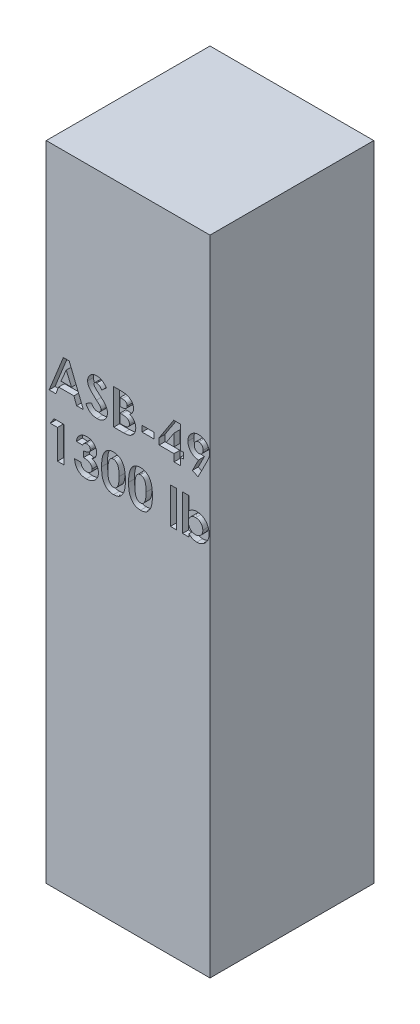
from build123d import *

# Parameters (mm, degrees)
SKETCH1_W           = 355.6
SKETCH1_H           = 1397
BOSS_EXTRUDE1_DEPTH = 355.6
SKETCH2_W           = 26.376923077
SKETCH2_H           = 12.7
SKETCH2_W_2         = 13.676923077
SKETCH2_H_2         = 78.153846154
CUT_EXTRUDE1_DEPTH  = 12.7


with BuildPart() as part:
    # Sketch1 → Boss-Extrude1 (new body)
    with BuildSketch(Plane.XY):
        Rectangle(SKETCH1_W, SKETCH1_H)
    extrude(amount=BOSS_EXTRUDE1_DEPTH)

    # Sketch2 → Cut-Extrude1 (cut)
    with BuildSketch(Plane.XY.offset(355.6)):
        Polygon((-140.661658654, 309.033333333), (-127.976923077, 309.033333333), (-97.203846154, 232.833333333), (-111.811899038, 232.833333333), (-117.734495192, 248.464102564), (-150.934615385, 248.464102564), (-156.857211538, 232.833333333), (-171.45, 232.833333333), align=None)
        Polygon((-134.326923077, 288.594270833), (-145.744711538, 262.141025641), (-122.909134615, 262.141025641), align=None, mode=Mode.SUBTRACT)
        with BuildLine():
            Line((-46.892307692, 298.851963141), (-57.119471154, 289.494871795))
            add(Edge.make_bspline(
                [(-57.119471154, 289.494871795), (-57.557558983, 290.112840222), (-58.398626523, 291.299253425), (-59.761909279, 292.887888667), (-61.119036113, 294.243112753), (-62.482579983, 295.359264183), (-63.86462682, 296.229561507), (-65.262777595, 296.845741626), (-66.669105798, 297.237453175), (-67.613941264, 297.286230688), (-68.079326923, 297.31025641)],
                knots=[0, 0, 0, 0, 0.002271477, 0.00436092, 0.006271414, 0.00801884, 0.009636869, 0.011154202, 0.012590762, 0.013985181, 0.013985181, 0.013985181, 0.013985181], degree=3))
            add(Edge.make_bspline(
                [(-68.079326923, 297.31025641), (-68.513425317, 297.29503261), (-69.351555263, 297.265639452), (-70.546371681, 296.973473654), (-71.607146713, 296.469238391), (-72.532845089, 295.809908365), (-73.266134779, 295.015568541), (-73.851609731, 294.182510307), (-74.181281326, 293.263002418), (-74.224672594, 292.631447308), (-74.246153846, 292.318790064)],
                knots=[0, 0, 0, 0, 0.001300704, 0.002511318, 0.003658488, 0.004806572, 0.005897204, 0.006887864, 0.007843812, 0.008781052, 0.008781052, 0.008781052, 0.008781052], degree=3))
            add(Edge.make_bspline(
                [(-74.246153846, 292.318790064), (-74.232692635, 292.001624164), (-74.205583625, 291.362896117), (-73.943747496, 290.426760617), (-73.549085685, 289.512047259), (-73.171970213, 288.955217713), (-72.979206731, 288.670592949)],
                knots=[0, 0, 0, 0, 0.000949467, 0.001912094, 0.002896265, 0.00392534, 0.00392534, 0.00392534, 0.00392534], degree=3))
            add(Edge.make_bspline(
                [(-72.979206731, 288.670592949), (-72.803963873, 288.449357098), (-72.400577959, 287.940101388), (-71.631403639, 287.133519725), (-70.665482233, 286.145386588), (-69.465643052, 285.009680978), (-68.081694719, 283.68555848), (-66.449489442, 282.225070854), (-64.616009207, 280.582988495), (-63.312813935, 279.439501804), (-62.629927885, 278.840304487)],
                knots=[0, 0, 0, 0, 0.000846316, 0.001948107, 0.00334052, 0.004992255, 0.00690348, 0.009086453, 0.011562161, 0.01428762, 0.01428762, 0.01428762, 0.01428762], degree=3))
            add(Edge.make_bspline(
                [(-62.629927885, 278.840304487), (-61.988941094, 278.285562752), (-60.772481336, 277.23277819), (-59.041700667, 275.738519539), (-57.520632718, 274.394171466), (-56.187118999, 273.219909758), (-55.061374278, 272.203413722), (-54.13866592, 271.339824518), (-53.407724607, 270.645954641), (-52.992227269, 270.226856812), (-52.814903846, 270.047996795)],
                knots=[0, 0, 0, 0, 0.002543119, 0.004826311, 0.006859633, 0.008633068, 0.010156836, 0.011409635, 0.012424461, 0.013180012, 0.013180012, 0.013180012, 0.013180012], degree=3))
            add(Edge.make_bspline(
                [(-52.814903846, 270.047996795), (-52.14217575, 269.319960917), (-50.848956097, 267.920420286), (-49.168226438, 265.751572454), (-47.784931563, 263.634334733), (-46.714788416, 261.528867861), (-45.90657327, 259.404794142), (-45.336770886, 257.210020781), (-44.995512446, 254.921613775), (-44.957624792, 253.360055353), (-44.938461538, 252.570232372)],
                knots=[0, 0, 0, 0, 0.002972646, 0.005714469, 0.008221044, 0.010548906, 0.012785704, 0.015025625, 0.017339784, 0.019708181, 0.019708181, 0.019708181, 0.019708181], degree=3))
            add(Edge.make_bspline(
                [(-44.938461538, 252.570232372), (-44.952101452, 251.80064674), (-44.978863469, 250.290691086), (-45.306646862, 248.081095904), (-45.774046742, 245.966417417), (-46.496728952, 243.969666317), (-47.37752975, 242.058066543), (-48.481740763, 240.261394741), (-49.778485188, 238.561467858), (-51.264753405, 236.988674166), (-52.908742539, 235.561472904), (-54.672077127, 234.290944631), (-56.571999943, 233.241961707), (-58.592278345, 232.378199091), (-60.731830923, 231.712917575), (-62.988108827, 231.221212531), (-65.364563186, 230.926098915), (-66.989616922, 230.895248288), (-67.819831731, 230.879487179)],
                knots=[0, 0, 0, 0, 0.002306747, 0.004525923, 0.006688305, 0.008793246, 0.010882856, 0.012992883, 0.015105559, 0.017286823, 0.019472356, 0.021628317, 0.023794413, 0.025969098, 0.028209175, 0.030505596, 0.032889291, 0.035379077, 0.035379077, 0.035379077, 0.035379077], degree=3))
            add(Edge.make_bspline(
                [(-67.819831731, 230.879487179), (-68.471543286, 230.891048977), (-69.762305921, 230.913947966), (-71.664694906, 231.100899151), (-73.501666523, 231.402618474), (-75.27115159, 231.835072394), (-76.981121948, 232.383050164), (-78.631647824, 233.052384018), (-80.211335089, 233.85344838), (-81.732136406, 234.769770182), (-83.186658805, 235.833740496), (-84.593294148, 237.023606796), (-85.938070399, 238.35766976), (-87.227446244, 239.832774378), (-88.453171897, 241.453097794), (-89.655369758, 243.196074005), (-90.780610535, 245.094050283), (-91.475721818, 246.425495996), (-91.830769231, 247.10556891)],
                knots=[0, 0, 0, 0, 0.0019548, 0.003871625, 0.005728622, 0.007535314, 0.009331074, 0.011111196, 0.012872436, 0.014639486, 0.01643174, 0.01827286, 0.020161767, 0.022108923, 0.02414528, 0.02625376, 0.028457977, 0.030759313, 0.030759313, 0.030759313, 0.030759313], degree=3))
            Line((-91.830769231, 247.10556891), (-79.802403846, 254.325641026))
            add(Edge.make_bspline(
                [(-79.802403846, 254.325641026), (-79.358292598, 253.553669411), (-78.506893378, 252.073733849), (-77.064117804, 250.085252851), (-75.586067886, 248.38244803), (-74.038572431, 246.995416571), (-72.440448407, 245.90561208), (-70.783976503, 245.126762185), (-69.067992913, 244.644654981), (-67.899142848, 244.585778556), (-67.316105769, 244.556410256)],
                knots=[0, 0, 0, 0, 0.002670183, 0.00511897, 0.007357642, 0.009422631, 0.011336233, 0.013139051, 0.014894194, 0.01664102, 0.01664102, 0.01664102, 0.01664102], degree=3))
            add(Edge.make_bspline(
                [(-67.316105769, 244.556410256), (-66.723073588, 244.580394002), (-65.572504787, 244.626925962), (-63.930215055, 245.056727645), (-62.424501645, 245.731547818), (-61.122974095, 246.69442315), (-60.020922626, 247.805727628), (-59.207545384, 249.042104674), (-58.696576314, 250.379834793), (-58.642554495, 251.309110127), (-58.615384615, 251.776482372)],
                knots=[0, 0, 0, 0, 0.001775994, 0.003445688, 0.005057657, 0.006697287, 0.008273297, 0.00972975, 0.011110822, 0.012508246, 0.012508246, 0.012508246, 0.012508246], degree=3))
            add(Edge.make_bspline(
                [(-58.615384615, 251.776482372), (-58.640474887, 252.21129619), (-58.691443372, 253.094578835), (-59.066861522, 254.407878095), (-59.653754599, 255.720580094), (-60.348090496, 256.797293787), (-61.054664213, 257.698796976), (-61.730308055, 258.479908709), (-62.553063524, 259.342900426), (-63.520844477, 260.288857706), (-64.620864002, 261.32610805), (-65.854048722, 262.454549887), (-67.234519907, 263.664242992), (-68.210239664, 264.488273984), (-68.720432692, 264.919150641)],
                knots=[0, 0, 0, 0, 0.00130321, 0.002647346, 0.004068578, 0.005605744, 0.00647595, 0.00750412, 0.008702644, 0.010051884, 0.011563602, 0.013238312, 0.015066286, 0.017069651, 0.017069651, 0.017069651, 0.017069651], degree=3))
            add(Edge.make_bspline(
                [(-68.720432692, 264.919150641), (-69.690329945, 265.739776722), (-71.551856338, 267.314806557), (-74.182429308, 269.641076041), (-76.552811092, 271.815188027), (-78.642528527, 273.864019293), (-80.478207847, 275.749732674), (-82.047417034, 277.487644654), (-83.332917611, 279.091160848), (-84.685629778, 280.990418475), (-85.970976795, 283.304794394), (-87.081881368, 286.089256921), (-87.802589366, 288.873366141), (-87.883334674, 290.742463725), (-87.923076923, 291.662419872)],
                knots=[0, 0, 0, 0, 0.00381134, 0.007315116, 0.010534208, 0.013459447, 0.016093434, 0.018428441, 0.020480981, 0.022255466, 0.025419366, 0.028392795, 0.031236119, 0.033992014, 0.033992014, 0.033992014, 0.033992014], degree=3))
            add(Edge.make_bspline(
                [(-87.923076923, 291.662419872), (-87.906548175, 292.314803393), (-87.873984765, 293.600069009), (-87.583514124, 295.489864828), (-87.149394685, 297.313359007), (-86.518928628, 299.063898607), (-85.700659811, 300.739291008), (-84.706904118, 302.347737961), (-83.522230405, 303.874435682), (-82.187183107, 305.31837208), (-80.716302795, 306.637965628), (-79.14448026, 307.802639158), (-77.480612156, 308.786339356), (-75.734877186, 309.6023901), (-73.896457756, 310.227025104), (-71.978897418, 310.66979753), (-69.979445783, 310.933144449), (-68.619461939, 310.968943407), (-67.926682692, 310.987179487)],
                knots=[0, 0, 0, 0, 0.001955992, 0.003853513, 0.00572314, 0.007572405, 0.009422488, 0.011307506, 0.013234031, 0.0152107, 0.017199649, 0.019153554, 0.021069832, 0.022988844, 0.024924539, 0.026883269, 0.028884539, 0.03096252, 0.03096252, 0.03096252, 0.03096252], degree=3))
            add(Edge.make_bspline(
                [(-67.926682692, 310.987179487), (-67.028875077, 310.954335772), (-65.240346824, 310.888907598), (-62.595956218, 310.377280657), (-60.013026035, 309.572693401), (-57.931652487, 308.602047396), (-56.275542405, 307.661782152), (-55.00628873, 306.796104358), (-53.714754796, 305.804423917), (-52.390525183, 304.683615784), (-51.058206129, 303.412562461), (-49.67991343, 302.021522372), (-48.274428009, 300.498473679), (-47.361085331, 299.410414755), (-46.892307692, 298.851963141)],
                knots=[0, 0, 0, 0, 0.00269178, 0.005362313, 0.008051322, 0.01079017, 0.01223288, 0.013761229, 0.015394594, 0.017116499, 0.018962989, 0.020916657, 0.022990822, 0.025177953, 0.025177953, 0.025177953, 0.025177953], degree=3))
        make_face()
        with BuildLine():
            Line((-31.261538462, 232.833333333), (-31.261538462, 309.033333333))
            Line((-31.261538462, 309.033333333), (-19.05, 309.033333333))
            add(Edge.make_bspline(
                [(-19.05, 309.033333333), (-18.195115952, 309.033430897), (-16.540931527, 309.03361968), (-14.154375105, 308.949811654), (-11.941045574, 308.841396583), (-9.907986607, 308.72010533), (-8.051737796, 308.511096267), (-6.375121871, 308.290823546), (-4.874788943, 308.02518822), (-3.947214621, 307.786905103), (-3.510817308, 307.674799679)],
                knots=[0, 0, 0, 0, 0.002564469, 0.004962198, 0.00716287, 0.009212911, 0.011070536, 0.012765162, 0.014286099, 0.01563741, 0.01563741, 0.01563741, 0.01563741], degree=3))
            add(Edge.make_bspline(
                [(-3.510817308, 307.674799679), (-2.937783327, 307.516672983), (-1.813306698, 307.206377641), (-0.202697319, 306.579722787), (1.325190345, 305.883151488), (2.768490784, 305.088493916), (4.118341559, 304.186156326), (5.369612777, 303.168977496), (6.549291262, 302.077786942), (7.615489324, 300.88217349), (8.579156703, 299.618786404), (9.416410878, 298.287956724), (10.143877446, 296.910033707), (10.726041247, 295.467677105), (11.164690734, 293.967529363), (11.485517138, 292.415996343), (11.693456092, 290.808168612), (11.713103596, 289.714310855), (11.723076923, 289.159054487)],
                knots=[0, 0, 0, 0, 0.001782281, 0.003497407, 0.005177603, 0.006817375, 0.008434611, 0.010041369, 0.011650517, 0.013250298, 0.014840877, 0.016412001, 0.017961848, 0.019509513, 0.021069549, 0.022644227, 0.024259229, 0.025924171, 0.025924171, 0.025924171, 0.025924171], degree=3))
            add(Edge.make_bspline(
                [(11.723076923, 289.159054487), (11.696999635, 288.4456958), (11.645669696, 287.041536873), (11.317770555, 284.97908145), (10.702908576, 283.029764632), (9.898376632, 281.157661245), (8.804464718, 279.369754249), (7.415408151, 277.666893743), (5.7537051, 275.996646099), (4.479087128, 274.995445301), (3.816105769, 274.474679487)],
                knots=[0, 0, 0, 0, 0.002140505, 0.004213322, 0.006241251, 0.008257657, 0.010312693, 0.012505889, 0.014837301, 0.017364428, 0.017364428, 0.017364428, 0.017364428], degree=3))
            add(Edge.make_bspline(
                [(3.816105769, 274.474679487), (4.353354056, 274.200418896), (5.406749309, 273.662669754), (6.902261098, 272.778770693), (8.286941767, 271.83863194), (9.566999803, 270.861169465), (10.715584526, 269.804947216), (11.780122926, 268.730826171), (12.708096204, 267.57726366), (13.537917877, 266.385374848), (14.259185388, 265.137901047), (14.887329856, 263.836948959), (15.417900956, 262.478074249), (15.867202287, 261.068192488), (16.202291338, 259.602454343), (16.420776526, 258.080335605), (16.588062442, 256.507027474), (16.601075714, 255.435329263), (16.607692308, 254.890424679)],
                knots=[0, 0, 0, 0, 0.001809333, 0.003547602, 0.005207217, 0.006828483, 0.008373813, 0.009885068, 0.011360751, 0.012808862, 0.014238349, 0.015678877, 0.017138686, 0.018611129, 0.0201145, 0.021642926, 0.023222554, 0.024856489, 0.024856489, 0.024856489, 0.024856489], degree=3))
            add(Edge.make_bspline(
                [(16.607692308, 254.890424679), (16.564755037, 253.849688079), (16.480018505, 251.795798573), (15.860466333, 248.78021707), (14.786359727, 245.921172292), (13.344056043, 243.230027306), (11.566860402, 240.784686344), (9.523595057, 238.64258889), (7.234831005, 236.82935095), (5.123169533, 235.605556007), (3.296748654, 234.78427516), (1.783958365, 234.27650755), (0.15925366, 233.806112404), (-1.607126148, 233.475791219), (-3.483159003, 233.173444948), (-5.487136343, 232.986770097), (-7.615312772, 232.860265151), (-9.077036337, 232.842492101), (-9.830288462, 232.833333333)],
                knots=[0, 0, 0, 0, 0.003121267, 0.006159807, 0.009188055, 0.012254419, 0.015292384, 0.018228951, 0.021108754, 0.02402266, 0.025526031, 0.027109416, 0.028805691, 0.030595864, 0.032495656, 0.034505117, 0.036630383, 0.038889982, 0.038889982, 0.038889982, 0.038889982], degree=3))
            Line((-9.830288462, 232.833333333), (-31.261538462, 232.833333333))
        make_face()
        with BuildLine():
            Line((-17.584615385, 295.356410256), (-17.584615385, 278.748717949))
            Line((-17.584615385, 278.748717949), (-13.951682692, 278.748717949))
            add(Edge.make_bspline(
                [(-13.951682692, 278.748717949), (-13.457934499, 278.75302362), (-12.504783494, 278.761335457), (-11.128057969, 278.868389037), (-9.847925563, 279.051029094), (-8.669241544, 279.305857918), (-7.581026041, 279.629453369), (-6.590230888, 280.018808386), (-5.701212433, 280.493863829), (-4.668378606, 281.201479873), (-3.576598771, 282.242768564), (-2.61551726, 283.747125823), (-2.049446668, 285.477130948), (-1.986401672, 286.697264518), (-1.953846154, 287.327323718)],
                knots=[0, 0, 0, 0, 0.001480964, 0.002858911, 0.004139031, 0.005357606, 0.006473163, 0.007541782, 0.008545642, 0.009489818, 0.011292636, 0.013028826, 0.014795547, 0.016681985, 0.016681985, 0.016681985, 0.016681985], degree=3))
            add(Edge.make_bspline(
                [(-1.953846154, 287.327323718), (-1.979896528, 287.917478842), (-2.030263879, 289.058520058), (-2.600224185, 290.660643546), (-3.485485218, 292.08045285), (-4.530660295, 293.052196208), (-5.514895725, 293.715868272), (-6.357658498, 294.152868065), (-7.282653925, 294.544065812), (-8.307788926, 294.843185144), (-9.427209419, 295.067633759), (-10.635477752, 295.232464387), (-11.934678606, 295.344655125), (-12.832039401, 295.352407831), (-13.2953125, 295.356410256)],
                knots=[0, 0, 0, 0, 0.001763421, 0.003409503, 0.005035648, 0.00674158, 0.007643344, 0.008592443, 0.00958463, 0.01065194, 0.011789523, 0.013007046, 0.014308915, 0.015698313, 0.015698313, 0.015698313, 0.015698313], degree=3))
            Line((-13.2953125, 295.356410256), (-17.584615385, 295.356410256))
        make_face(mode=Mode.SUBTRACT)
        with BuildLine():
            Line((-17.584615385, 266.048717949), (-17.584615385, 246.51025641))
            Line((-17.584615385, 246.51025641), (-13.646394231, 246.51025641))
            add(Edge.make_bspline(
                [(-13.646394231, 246.51025641), (-12.867802894, 246.514704474), (-11.370863894, 246.52325643), (-9.226501429, 246.626584407), (-7.276739857, 246.812814878), (-5.526745311, 247.045308619), (-3.973837343, 247.360301273), (-2.623265154, 247.760774065), (-1.456507397, 248.201363889), (-0.480560009, 248.745544633), (0.316733098, 249.378836073), (1.036206534, 250.026075136), (1.622820342, 250.772726545), (2.086960134, 251.586738624), (2.488672304, 252.447890724), (2.730956718, 253.389810526), (2.915423567, 254.384581786), (2.925575272, 255.072643553), (2.930769231, 255.424679487)],
                knots=[0, 0, 0, 0, 0.002335656, 0.004490591, 0.006437807, 0.008210124, 0.009784803, 0.011185475, 0.012432682, 0.013519462, 0.014520882, 0.015482056, 0.016416558, 0.017353799, 0.01828992, 0.019256533, 0.020262828, 0.021317068, 0.021317068, 0.021317068, 0.021317068], degree=3))
            add(Edge.make_bspline(
                [(2.930769231, 255.424679487), (2.91931506, 255.827238114), (2.897005417, 256.611314027), (2.714802289, 257.757324651), (2.383679689, 258.827201606), (1.966614618, 259.848303091), (1.386246413, 260.784070113), (0.696498635, 261.666886022), (-0.136892764, 262.466855947), (-1.074090011, 263.232365058), (-2.16723781, 263.902609757), (-3.416849037, 264.484165754), (-4.829712259, 264.969859907), (-6.41020397, 265.356569909), (-8.151395416, 265.684765343), (-10.065995382, 265.880734247), (-12.138058416, 266.026484934), (-13.574860644, 266.041138548), (-14.318028846, 266.048717949)],
                knots=[0, 0, 0, 0, 0.001207434, 0.002351757, 0.003467314, 0.004561678, 0.005650707, 0.006759244, 0.007914208, 0.009108545, 0.010383559, 0.011749277, 0.013236129, 0.014857682, 0.016627104, 0.018547087, 0.020627589, 0.022856666, 0.022856666, 0.022856666, 0.022856666], degree=3))
            Line((-14.318028846, 266.048717949), (-17.584615385, 266.048717949))
        make_face(mode=Mode.SUBTRACT)
        with Locations((43.473076924, 260.675641026)):
            Rectangle(SKETCH2_W, SKETCH2_H)
        Polygon((99.066105769, 310.987179487), (113.323076923, 310.987179487), (113.323076923, 261.164102564), (120.161538462, 261.164102564), (120.161538462, 248.464102564), (113.323076923, 248.464102564), (113.323076923, 232.833333333), (99.646153846, 232.833333333), (99.646153846, 248.464102564), (67.407692308, 248.464102564), (67.407692308, 262.308934295), align=None)
        Polygon((99.646153846, 261.164102564), (99.646153846, 287.098357372), (82.778966346, 261.164102564), align=None, mode=Mode.SUBTRACT)
        with BuildLine():
            Line((151.728365385, 230.879487179), (139.608413462, 236.98525641))
            Line((139.608413462, 236.98525641), (152.888461538, 263.117948718))
            add(Edge.make_bspline(
                [(152.888461538, 263.117948718), (152.103845813, 263.13794753), (150.563455308, 263.177210036), (148.295350461, 263.503481108), (146.126416403, 264.06044665), (144.031088544, 264.801908098), (142.038344607, 265.795913999), (140.124020978, 266.982207879), (138.314618366, 268.407522923), (136.601653245, 270.009635967), (135.037661343, 271.780489469), (133.680149456, 273.68501244), (132.4969217, 275.674892711), (131.576778896, 277.795053271), (130.837715516, 280.005979592), (130.297718544, 282.319115674), (129.994686525, 284.74461007), (129.952331227, 286.395375029), (129.930769231, 287.235737179)],
                knots=[0, 0, 0, 0, 0.002353148, 0.0046198, 0.00685592, 0.009062514, 0.011274328, 0.013523384, 0.015807342, 0.018172343, 0.020551733, 0.022881596, 0.025180197, 0.027483305, 0.029800281, 0.032166316, 0.03459734, 0.037118235, 0.037118235, 0.037118235, 0.037118235], degree=3))
            add(Edge.make_bspline(
                [(129.930769231, 287.235737179), (129.950769158, 288.050880184), (129.990178601, 289.657102609), (130.317477833, 292.014514417), (130.856127661, 294.277974162), (131.595135926, 296.447097316), (132.578943988, 298.507257103), (133.730466284, 300.490710846), (135.138150043, 302.356423028), (136.728353797, 304.112470318), (138.468747412, 305.718943531), (140.315158946, 307.131426071), (142.259193034, 308.312125753), (144.275866914, 309.303695671), (146.401633429, 310.04453503), (148.605772874, 310.603492836), (150.90470463, 310.926091374), (152.465171559, 310.966653842), (153.254807692, 310.987179487)],
                knots=[0, 0, 0, 0, 0.002444644, 0.00481712, 0.007123716, 0.009416684, 0.011676901, 0.013962338, 0.016285591, 0.018673924, 0.021061282, 0.023381525, 0.025635548, 0.027874793, 0.030110132, 0.032375858, 0.034687851, 0.037056248, 0.037056248, 0.037056248, 0.037056248], degree=3))
            add(Edge.make_bspline(
                [(153.254807692, 310.987179487), (154.08046779, 310.970184167), (155.704016656, 310.936765169), (158.080674172, 310.567999708), (160.354563885, 310.002246034), (162.534924976, 309.233837129), (164.594689182, 308.1909472), (166.551091549, 306.941036357), (168.397624461, 305.456449501), (170.114457516, 303.779977025), (171.675897992, 301.956499541), (173.059920687, 300.047758514), (174.22255851, 298.057486077), (175.174830004, 296.003444726), (175.916644704, 293.882416558), (176.42654777, 291.691392981), (176.765066854, 289.434120741), (176.803583569, 287.903523346), (176.823076923, 287.128886218)],
                knots=[0, 0, 0, 0, 0.002475144, 0.004867036, 0.007195698, 0.009498806, 0.011785669, 0.014106062, 0.016451822, 0.018880593, 0.021294545, 0.023645712, 0.025944313, 0.028198078, 0.030428356, 0.032672018, 0.03493867, 0.037261321, 0.037261321, 0.037261321, 0.037261321], degree=3))
            add(Edge.make_bspline(
                [(176.823076923, 287.128886218), (176.812439218, 286.538088874), (176.791012488, 285.34809019), (176.580328607, 283.563558171), (176.260678708, 281.774080143), (175.889657337, 280.269572949), (175.500693045, 279.001364768), (175.122186492, 277.925525319), (174.636551444, 276.731141535), (174.094291371, 275.410207732), (173.466290386, 273.968516367), (172.739528043, 272.412959273), (171.957927867, 270.72046599), (171.381811383, 269.563162157), (171.083653846, 268.964222756)],
                knots=[0, 0, 0, 0, 0.001771725, 0.003568653, 0.005383131, 0.007223111, 0.008212947, 0.009361944, 0.010643155, 0.012080364, 0.013645767, 0.015360078, 0.017231138, 0.019238163, 0.019238163, 0.019238163, 0.019238163], degree=3))
            Line((171.083653846, 268.964222756), (151.728365385, 230.879487179))
        make_face()
        with BuildLine():
            add(Edge.make_bspline(
                [(153.560096154, 275.817948718), (154.215437325, 275.856530552), (155.495825593, 275.931910719), (157.33501819, 276.514766238), (158.981002054, 277.512190321), (160.439897305, 278.8372815), (161.645483685, 280.453953352), (162.522023874, 282.29439055), (163.061945649, 284.320479667), (163.117545266, 285.731312643), (163.146153846, 286.457251603)],
                knots=[0, 0, 0, 0, 0.001963897, 0.00383701, 0.005719244, 0.007696856, 0.009714822, 0.011728917, 0.013780037, 0.015954079, 0.015954079, 0.015954079, 0.015954079], degree=3))
            add(Edge.make_bspline(
                [(163.146153846, 286.457251603), (163.11169793, 287.198291768), (163.044672946, 288.63979182), (162.499578939, 290.714514835), (161.568122924, 292.589941391), (160.300930295, 294.220203544), (158.821499426, 295.584524696), (157.167122283, 296.581124557), (155.377970581, 297.197389968), (154.139815007, 297.272374481), (153.514302885, 297.31025641)],
                knots=[0, 0, 0, 0, 0.002220908, 0.004320196, 0.006381798, 0.008460956, 0.010481691, 0.012384853, 0.014219126, 0.016091928, 0.016091928, 0.016091928, 0.016091928], degree=3))
            add(Edge.make_bspline(
                [(153.514302885, 297.31025641), (152.853171681, 297.273326418), (151.555045974, 297.20081468), (149.693009835, 296.586029183), (147.976504818, 295.60856736), (146.47751999, 294.23961713), (145.180206103, 292.630825004), (144.275553713, 290.749068047), (143.703239247, 288.68882326), (143.640113948, 287.244738139), (143.607692308, 286.503044872)],
                knots=[0, 0, 0, 0, 0.001979084, 0.003885915, 0.005820888, 0.007864326, 0.009940793, 0.011981949, 0.014085174, 0.016306082, 0.016306082, 0.016306082, 0.016306082], degree=3))
            add(Edge.make_bspline(
                [(143.607692308, 286.503044872), (143.641558718, 285.771923896), (143.70742535, 284.349969941), (144.259454703, 282.312390078), (145.158655205, 280.462213135), (146.387926439, 278.832791526), (147.902085878, 277.501171479), (149.621297349, 276.514371976), (151.539037975, 275.930330306), (152.874282986, 275.856083579), (153.560096154, 275.817948718)],
                knots=[0, 0, 0, 0, 0.002190485, 0.004260264, 0.006280999, 0.008329505, 0.010341284, 0.012289517, 0.014235537, 0.016290573, 0.016290573, 0.016290573, 0.016290573], degree=3))
        make_face(mode=Mode.SUBTRACT)
        Polygon((-160.841225962, 183.964102564), (-139.7, 183.964102564), (-139.7, 107.764102564), (-153.376923077, 107.764102564), (-153.376923077, 171.264102564), (-169.007692308, 171.264102564), align=None)
        with BuildLine():
            Line((-98.669230769, 165.402564103), (-112.346153846, 165.402564103))
            add(Edge.make_bspline(
                [(-112.346153846, 165.402564103), (-112.249589568, 166.086224695), (-112.060281697, 167.426496001), (-111.607293278, 169.366874972), (-111.065470248, 171.207457221), (-110.389031876, 172.942414), (-109.595679714, 174.57483584), (-108.693481266, 176.110324418), (-107.672683428, 177.542289128), (-106.890231072, 178.404910353), (-106.499879808, 178.83525641)],
                knots=[0, 0, 0, 0, 0.002070398, 0.004058879, 0.005971262, 0.007822289, 0.009638243, 0.01141056, 0.013160185, 0.014902002, 0.014902002, 0.014902002, 0.014902002], degree=3))
            add(Edge.make_bspline(
                [(-106.499879808, 178.83525641), (-105.936849833, 179.40306685), (-104.827176923, 180.522161553), (-102.972783342, 181.955598253), (-101.029036408, 183.196140236), (-98.956953419, 184.179650888), (-96.788777554, 184.975688826), (-94.507266721, 185.510389307), (-92.121744003, 185.865167797), (-90.493924851, 185.900114714), (-89.663221154, 185.917948718)],
                knots=[0, 0, 0, 0, 0.002396563, 0.004723374, 0.007014512, 0.00930163, 0.011590378, 0.01393022, 0.016319919, 0.018810313, 0.018810313, 0.018810313, 0.018810313], degree=3))
            add(Edge.make_bspline(
                [(-89.663221154, 185.917948718), (-88.924682824, 185.900513275), (-87.472865289, 185.866238708), (-85.339058815, 185.591101083), (-83.304652914, 185.108540326), (-81.348143321, 184.477602965), (-79.498303917, 183.619107239), (-77.714306953, 182.622576426), (-76.045997365, 181.400289971), (-74.489471628, 180.019229285), (-73.059505872, 178.525476955), (-71.821149262, 176.928778559), (-70.756511863, 175.271785591), (-69.879391465, 173.540731574), (-69.205005073, 171.732687356), (-68.736960916, 169.858097763), (-68.430614652, 167.92109922), (-68.400094559, 166.604547401), (-68.384615385, 165.93681891)],
                knots=[0, 0, 0, 0, 0.002215235, 0.004354706, 0.006439292, 0.008481134, 0.010509982, 0.012547196, 0.014602062, 0.016700018, 0.018783877, 0.020796062, 0.022752351, 0.024684251, 0.026606598, 0.028528037, 0.030473098, 0.032474834, 0.032474834, 0.032474834, 0.032474834], degree=3))
            add(Edge.make_bspline(
                [(-68.384615385, 165.93681891), (-68.416379576, 165.109892776), (-68.478913502, 163.481929457), (-68.992049645, 161.099284183), (-69.795247243, 158.821050102), (-70.955544296, 156.679103135), (-72.406211136, 154.679272457), (-74.186130763, 152.888418412), (-76.244606447, 151.278462836), (-77.789931562, 150.413272512), (-78.58125, 149.970232372)],
                knots=[0, 0, 0, 0, 0.002478531, 0.004879465, 0.007279088, 0.009703442, 0.012161204, 0.014665407, 0.017254606, 0.01997193, 0.01997193, 0.01997193, 0.01997193], degree=3))
            add(Edge.make_bspline(
                [(-78.58125, 149.970232372), (-78.038101163, 149.791905173), (-76.97083806, 149.441500224), (-75.453851885, 148.751381644), (-74.011371376, 147.997196426), (-72.668235525, 147.121032013), (-71.411085227, 146.158316608), (-70.247584218, 145.100820576), (-69.170780849, 143.950849748), (-68.198253497, 142.702079722), (-67.335097474, 141.374482143), (-66.560633536, 139.998723729), (-65.923206545, 138.553940858), (-65.383226526, 137.056633922), (-64.972116483, 135.493345913), (-64.682658277, 133.870134446), (-64.515344329, 132.190702173), (-64.489826099, 131.052887826), (-64.476923077, 130.477564103)],
                knots=[0, 0, 0, 0, 0.001713767, 0.003367476, 0.004992689, 0.006593125, 0.008171573, 0.009738464, 0.011304463, 0.012892257, 0.014479904, 0.016051472, 0.017623041, 0.019211494, 0.02082209, 0.022465906, 0.024153367, 0.025879327, 0.025879327, 0.025879327, 0.025879327], degree=3))
            add(Edge.make_bspline(
                [(-64.476923077, 130.477564103), (-64.503079236, 129.632071818), (-64.554653855, 127.964933228), (-64.882541143, 125.509408694), (-65.493008193, 123.168284214), (-66.296111414, 120.914621617), (-67.367363949, 118.777514867), (-68.628048086, 116.707920279), (-70.17768219, 114.777610825), (-71.899834414, 112.935554123), (-73.812384858, 111.260838652), (-75.885900681, 109.808935698), (-78.074787046, 108.562944639), (-80.392892419, 107.551413598), (-82.839411436, 106.772419006), (-85.408891021, 106.209325807), (-88.112127424, 105.864816072), (-89.957297768, 105.828700758), (-90.899639423, 105.81025641)],
                knots=[0, 0, 0, 0, 0.002536835, 0.005002122, 0.007412258, 0.009783162, 0.012165635, 0.014571659, 0.017039072, 0.019576687, 0.022129819, 0.024649605, 0.02715827, 0.029673752, 0.032222591, 0.034848471, 0.037555917, 0.040381856, 0.040381856, 0.040381856, 0.040381856], degree=3))
            add(Edge.make_bspline(
                [(-90.899639423, 105.81025641), (-91.79107943, 105.829702857), (-93.534172401, 105.867727811), (-96.083810683, 106.196853054), (-98.50700053, 106.72775878), (-100.809925957, 107.476114425), (-102.983677144, 108.446603806), (-105.047966499, 109.602238904), (-106.961601588, 111.009674063), (-108.745904074, 112.605375002), (-110.361292743, 114.395660851), (-111.805069798, 116.33906053), (-113.045399701, 118.44296399), (-114.087369063, 120.698382479), (-114.922832038, 123.109272677), (-115.58184278, 125.67073192), (-116.042172569, 128.387764504), (-116.182366971, 130.257140723), (-116.253846154, 131.21025641)],
                knots=[0, 0, 0, 0, 0.00267341, 0.0052275, 0.007697744, 0.010106478, 0.012477775, 0.014829289, 0.017189408, 0.01958908, 0.021998974, 0.024410801, 0.026840196, 0.029312514, 0.031851828, 0.034484133, 0.03723952, 0.040105738, 0.040105738, 0.040105738, 0.040105738], degree=3))
            Line((-116.253846154, 131.21025641), (-102.576923077, 131.21025641))
            add(Edge.make_bspline(
                [(-102.576923077, 131.21025641), (-102.490253842, 130.731017331), (-102.321442777, 129.797573546), (-101.992187149, 128.446154452), (-101.56312113, 127.198711158), (-101.067014059, 126.044156425), (-100.531143734, 124.967331351), (-99.883684237, 124.008005744), (-99.172077999, 123.140129982), (-98.145225008, 122.108389712), (-96.677267932, 121.048319657), (-94.695039551, 120.127068349), (-92.489998193, 119.587101898), (-90.948454372, 119.52122765), (-90.151682692, 119.487179487)],
                knots=[0, 0, 0, 0, 0.001460926, 0.002845536, 0.004168179, 0.005412861, 0.006614395, 0.007770165, 0.008876388, 0.009977333, 0.012129833, 0.014267398, 0.016499816, 0.018888101, 0.018888101, 0.018888101, 0.018888101], degree=3))
            add(Edge.make_bspline(
                [(-90.151682692, 119.487179487), (-89.728887475, 119.494429723), (-88.900726233, 119.508631312), (-87.684280683, 119.666036918), (-86.52544502, 119.92528407), (-85.422060849, 120.277591341), (-84.367103964, 120.719230533), (-83.38073037, 121.288697842), (-82.442835306, 121.950784883), (-81.563614548, 122.695146482), (-80.751196448, 123.506234165), (-80.075216811, 124.404375974), (-79.457420337, 125.317048579), (-79.000493613, 126.303962239), (-78.600127364, 127.312010455), (-78.355082768, 128.377782217), (-78.1700565, 129.4789205), (-78.159303516, 130.232491203), (-78.153846154, 130.61494391)],
                knots=[0, 0, 0, 0, 0.001267774, 0.002483286, 0.003672051, 0.004825803, 0.005954235, 0.007095908, 0.008235129, 0.00939412, 0.010549083, 0.011669642, 0.012761981, 0.013847474, 0.014924779, 0.01600952, 0.017121311, 0.018267058, 0.018267058, 0.018267058, 0.018267058], degree=3))
            add(Edge.make_bspline(
                [(-78.153846154, 130.61494391), (-78.168334428, 131.033221106), (-78.197177261, 131.86591516), (-78.43282623, 133.081057041), (-78.804965759, 134.249925596), (-79.32191302, 135.367344524), (-80.012238474, 136.429195242), (-80.826814808, 137.45678169), (-81.829817169, 138.396619827), (-82.930245083, 139.325621343), (-84.20630916, 140.135430479), (-85.59586329, 140.882765325), (-87.13542711, 141.47741314), (-88.787418494, 142.008543782), (-90.583086402, 142.396473352), (-92.511280402, 142.678148031), (-94.568890035, 142.887811175), (-95.987227095, 142.917890806), (-96.715384615, 142.933333333)],
                knots=[0, 0, 0, 0, 0.001254007, 0.002496441, 0.00369846, 0.004927697, 0.006176864, 0.007490403, 0.008850565, 0.010292952, 0.011804438, 0.013374894, 0.015018923, 0.016747244, 0.018576747, 0.020521808, 0.022592038, 0.024776184, 0.024776184, 0.024776184, 0.024776184], degree=3))
            Line((-96.715384615, 142.933333333), (-96.715384615, 155.633333333))
            add(Edge.make_bspline(
                [(-96.715384615, 155.633333333), (-95.808785197, 155.71054224), (-94.112717224, 155.854984816), (-91.758483937, 156.192768799), (-89.776522982, 156.644272708), (-88.119197899, 157.188987735), (-86.74306134, 157.888543742), (-85.54087604, 158.660822683), (-84.505497192, 159.557711809), (-83.630463177, 160.552466006), (-82.930463189, 161.620738733), (-82.435043978, 162.745925867), (-82.107895014, 163.893212729), (-82.076897675, 164.677922363), (-82.061538462, 165.066746795)],
                knots=[0, 0, 0, 0, 0.002729431, 0.005106225, 0.007127882, 0.008822233, 0.010324054, 0.011746596, 0.013099286, 0.01441893, 0.015710286, 0.016912983, 0.018097821, 0.019261527, 0.019261527, 0.019261527, 0.019261527], degree=3))
            add(Edge.make_bspline(
                [(-82.061538462, 165.066746795), (-82.088037501, 165.562844551), (-82.139758017, 166.531122343), (-82.541447562, 167.91693184), (-83.2387351, 169.152266144), (-84.17367525, 170.234525768), (-85.31293233, 171.138510117), (-86.648341341, 171.794787342), (-88.150923831, 172.180379515), (-89.208071576, 172.220352431), (-89.754807692, 172.241025641)],
                knots=[0, 0, 0, 0, 0.001487009, 0.002902326, 0.004282639, 0.005711473, 0.007168086, 0.008615312, 0.010144347, 0.011782199, 0.011782199, 0.011782199, 0.011782199], degree=3))
            add(Edge.make_bspline(
                [(-89.754807692, 172.241025641), (-90.25036251, 172.216633428), (-91.23369505, 172.168231806), (-92.671621546, 171.806974921), (-94.03717265, 171.198843914), (-95.302071654, 170.360267094), (-96.448059484, 169.353171882), (-97.388584858, 168.160476644), (-98.170869271, 166.853637819), (-98.502459032, 165.888151542), (-98.669230769, 165.402564103)],
                knots=[0, 0, 0, 0, 0.001485676, 0.002948037, 0.004417312, 0.005949924, 0.007485042, 0.008972599, 0.010491083, 0.012027567, 0.012027567, 0.012027567, 0.012027567], degree=3))
        make_face()
        with BuildLine():
            add(Edge.make_bspline(
                [(-31.978966346, 185.917948718), (-31.316946503, 185.908120847), (-30.015238613, 185.888796626), (-28.098067918, 185.679499578), (-26.251302475, 185.363310109), (-24.467717507, 184.922336057), (-22.76015144, 184.338722606), (-21.116176255, 183.64014731), (-19.555360016, 182.789968454), (-18.057797326, 181.829647772), (-16.624065049, 180.742428624), (-15.288621937, 179.502942658), (-14.027079961, 178.139710499), (-12.86674686, 176.632122521), (-11.781926704, 174.993891835), (-10.776184029, 173.224758672), (-9.857218045, 171.316064307), (-9.014729335, 169.264364352), (-8.26137327, 167.038904709), (-7.62682239, 164.614158391), (-7.082588831, 161.989571667), (-6.623217307, 159.15861154), (-6.276006682, 156.11751499), (-6.04197973, 152.868302368), (-5.881379359, 149.41723768), (-5.868272276, 147.04983566), (-5.861538462, 145.833573718)],
                knots=[0, 0, 0, 0, 0.001985314, 0.003903658, 0.005778263, 0.007603431, 0.009408768, 0.011186598, 0.012955494, 0.014733849, 0.016519851, 0.01834553, 0.020192777, 0.022085812, 0.024045968, 0.026083183, 0.028185909, 0.030396933, 0.032733238, 0.035228773, 0.037911145, 0.040771952, 0.043829793, 0.047090275, 0.050543411, 0.054191895, 0.054191895, 0.054191895, 0.054191895], degree=3))
            add(Edge.make_bspline(
                [(-5.861538462, 145.833573718), (-5.868815895, 144.602094971), (-5.882955819, 142.209353857), (-6.035303526, 138.726723977), (-6.297653476, 135.453920123), (-6.635789024, 132.391280885), (-7.098942233, 129.540423595), (-7.641359022, 126.893966451), (-8.285926095, 124.452868727), (-9.064097467, 122.222630736), (-9.901486574, 120.167327547), (-10.822966325, 118.262354682), (-11.812475458, 116.502552422), (-12.847317617, 114.861371756), (-13.984226654, 113.387193856), (-15.167866003, 112.029888965), (-16.449773433, 110.841158568), (-17.775975687, 109.759740834), (-19.195056917, 108.825178893), (-20.692382511, 108.007826427), (-22.294647185, 107.3448565), (-23.972644379, 106.768240668), (-25.754975896, 106.354292717), (-27.613320732, 106.025838622), (-29.568659226, 105.844314742), (-30.899932429, 105.82179551), (-31.582091346, 105.81025641)],
                knots=[0, 0, 0, 0, 0.003694274, 0.007177909, 0.010454786, 0.013542956, 0.016418832, 0.019116147, 0.021645117, 0.023986353, 0.026197377, 0.028300103, 0.030329812, 0.03225216, 0.034114482, 0.035909464, 0.037648068, 0.039352565, 0.041037539, 0.042738204, 0.044461935, 0.046233463, 0.048054989, 0.049944636, 0.051891852, 0.053938196, 0.053938196, 0.053938196, 0.053938196], degree=3))
            add(Edge.make_bspline(
                [(-31.582091346, 105.81025641), (-32.264231851, 105.822018092), (-33.600535068, 105.845059053), (-35.56116099, 106.024488915), (-37.42935412, 106.355623291), (-39.225786744, 106.771418654), (-40.937955972, 107.34358068), (-42.574071606, 108.026386192), (-44.121553332, 108.838638786), (-45.584685881, 109.775378169), (-46.958473705, 110.8495604), (-48.264265458, 112.049695895), (-49.499172652, 113.37274262), (-50.644409287, 114.833519794), (-51.718731026, 116.412529087), (-52.71093439, 118.127802017), (-53.620423093, 119.976841188), (-54.475646108, 121.96222397), (-55.218726654, 124.126693378), (-55.880033837, 126.48957785), (-56.421759287, 129.070573974), (-56.857451143, 131.868852581), (-57.205307271, 134.878485394), (-57.464072247, 138.100925076), (-57.617266176, 141.537672562), (-57.631257812, 143.8999203), (-57.638461538, 145.116145833)],
                knots=[0, 0, 0, 0, 0.002046344, 0.004008757, 0.005898404, 0.007734772, 0.009535262, 0.011307119, 0.013048201, 0.014771526, 0.016511938, 0.018272913, 0.02008739, 0.021934953, 0.02383591, 0.025812579, 0.02787418, 0.030014795, 0.032293339, 0.034733976, 0.037371543, 0.04019979, 0.043227307, 0.046458537, 0.049896422, 0.053544907, 0.053544907, 0.053544907, 0.053544907], degree=3))
            add(Edge.make_bspline(
                [(-57.638461538, 145.116145833), (-57.625412662, 146.805995466), (-57.600234687, 150.0665821), (-57.281160896, 154.777181774), (-56.812841496, 159.131315177), (-56.124991233, 163.121698918), (-55.274473897, 166.763112214), (-54.185342161, 170.031567341), (-52.945444907, 172.972290706), (-51.888893156, 174.714392932), (-51.380048077, 175.553405449)],
                knots=[0, 0, 0, 0, 0.005068616, 0.00977996, 0.014157657, 0.018200453, 0.02192128, 0.025362958, 0.028527852, 0.031468185, 0.031468185, 0.031468185, 0.031468185], degree=3))
            add(Edge.make_bspline(
                [(-51.380048077, 175.553405449), (-50.788387256, 176.377651084), (-49.631573767, 177.989213716), (-47.608853044, 180.104894212), (-45.435702982, 181.914327773), (-43.067488318, 183.376565297), (-40.541663352, 184.529685927), (-37.836542594, 185.344122041), (-34.962115599, 185.818650471), (-32.988198635, 185.884355026), (-31.978966346, 185.917948718)],
                knots=[0, 0, 0, 0, 0.003040687, 0.005945142, 0.008753671, 0.011502709, 0.01426932, 0.017060414, 0.019953818, 0.022980834, 0.022980834, 0.022980834, 0.022980834], degree=3))
        make_face()
        with BuildLine():
            add(Edge.make_bspline(
                [(-31.643149038, 172.241025641), (-32.241620466, 172.212659285), (-33.414942153, 172.15704617), (-35.117487824, 171.684969284), (-36.72288209, 170.955821081), (-37.94406263, 170.078405221), (-38.858104119, 169.237296898), (-39.496751461, 168.476121219), (-40.112626165, 167.626704021), (-40.656597718, 166.650715471), (-41.170248861, 165.583223992), (-41.672240854, 164.419383812), (-42.083742472, 163.130608499), (-42.488031902, 161.738846062), (-42.842227167, 160.205617967), (-43.138965149, 158.518391766), (-43.404074452, 156.666195272), (-43.588991353, 154.647815294), (-43.761389398, 152.465363555), (-43.88497248, 150.113978399), (-43.936639465, 147.59429418), (-43.953062828, 145.859025051), (-43.961538462, 144.963501603)],
                knots=[0, 0, 0, 0, 0.001792449, 0.003514151, 0.005262578, 0.007058338, 0.007997937, 0.008983055, 0.010033531, 0.011141122, 0.012329004, 0.013587741, 0.014939311, 0.016383957, 0.017935382, 0.019657016, 0.021522151, 0.023546803, 0.025736064, 0.028089955, 0.030609325, 0.033296037, 0.033296037, 0.033296037, 0.033296037], degree=3))
            add(Edge.make_bspline(
                [(-43.961538462, 144.963501603), (-43.947588596, 143.803307683), (-43.920838696, 141.578549822), (-43.780735217, 138.379270551), (-43.499909422, 135.467668802), (-43.150618833, 132.82401157), (-42.660025937, 130.46544368), (-42.095567054, 128.369650894), (-41.398510522, 126.563349479), (-40.592927389, 125.020416256), (-39.700707772, 123.707846168), (-38.732164128, 122.592155682), (-37.720271899, 121.626020359), (-36.633446638, 120.841240542), (-35.474281184, 120.239821465), (-34.252452436, 119.807228151), (-32.967183941, 119.542419768), (-32.087045325, 119.505699358), (-31.643149038, 119.487179487)],
                knots=[0, 0, 0, 0, 0.003480824, 0.006674738, 0.009603161, 0.012254078, 0.014669959, 0.016825434, 0.01875866, 0.020465615, 0.022036368, 0.023508258, 0.02489051, 0.026224903, 0.027515266, 0.028794658, 0.030102865, 0.031434024, 0.031434024, 0.031434024, 0.031434024], degree=3))
            add(Edge.make_bspline(
                [(-31.643149038, 119.487179487), (-31.214485865, 119.499852159), (-30.375216673, 119.524663674), (-29.151374231, 119.779350542), (-27.994021855, 120.193416073), (-26.906653954, 120.779140836), (-25.885381164, 121.523979491), (-24.935194837, 122.431205174), (-24.063261088, 123.509860812), (-23.555268528, 124.310382824), (-23.293509615, 124.722876603)],
                knots=[0, 0, 0, 0, 0.001284481, 0.002514854, 0.003731612, 0.004960848, 0.006206559, 0.007512984, 0.008890931, 0.010355759, 0.010355759, 0.010355759, 0.010355759], degree=3))
            add(Edge.make_bspline(
                [(-23.293509615, 124.722876603), (-22.985332581, 125.286536168), (-22.339110333, 126.468484566), (-21.591300831, 128.462978416), (-20.961836472, 130.712437835), (-20.420065702, 133.223863354), (-20.049527545, 136.007160344), (-19.730420536, 139.04467968), (-19.576507296, 142.351717078), (-19.551472469, 144.642844518), (-19.538461538, 145.833573718)],
                knots=[0, 0, 0, 0, 0.001925255, 0.004037103, 0.006370763, 0.008930503, 0.011736833, 0.014789755, 0.018091144, 0.02166354, 0.02166354, 0.02166354, 0.02166354], degree=3))
            add(Edge.make_bspline(
                [(-19.538461538, 145.833573718), (-19.54348738, 147.034639022), (-19.553161266, 149.3464847), (-19.73064907, 152.66541113), (-19.977814398, 155.6966996), (-20.339345921, 158.433582473), (-20.804521936, 160.882703705), (-21.377853131, 163.043903193), (-22.05376796, 164.921440245), (-22.855322397, 166.5134427), (-23.743093738, 167.866426399), (-24.685490116, 169.027181467), (-25.686496369, 170.018204858), (-26.744438488, 170.843225968), (-27.883802912, 171.473603973), (-29.082826296, 171.918702994), (-30.34396673, 172.187972975), (-31.204243046, 172.223102727), (-31.643149038, 172.241025641)],
                knots=[0, 0, 0, 0, 0.003602695, 0.006934573, 0.009968048, 0.01272483, 0.015212556, 0.017441632, 0.019426536, 0.021187775, 0.022775422, 0.024272581, 0.025664994, 0.026993086, 0.028284442, 0.029554695, 0.030818051, 0.032133983, 0.032133983, 0.032133983, 0.032133983], degree=3))
        make_face(mode=Mode.SUBTRACT)
        with BuildLine():
            add(Edge.make_bspline(
                [(26.636418269, 185.917948718), (27.298438112, 185.908120847), (28.600146003, 185.888796626), (30.517316698, 185.679499578), (32.364082141, 185.363310109), (34.147667109, 184.922336057), (35.855233175, 184.338722606), (37.49920836, 183.64014731), (39.0600246, 182.789968454), (40.55758729, 181.829647772), (41.991319567, 180.742428624), (43.326762679, 179.502942658), (44.588304655, 178.139710499), (45.748637755, 176.632122521), (46.833457912, 174.993891835), (47.839200586, 173.224758672), (48.758166571, 171.316064307), (49.60065528, 169.264364352), (50.354011345, 167.038904709), (50.988562225, 164.614158391), (51.532795784, 161.989571667), (51.992167308, 159.15861154), (52.339377934, 156.11751499), (52.573404885, 152.868302368), (52.734005257, 149.41723768), (52.747112339, 147.04983566), (52.753846154, 145.833573718)],
                knots=[0, 0, 0, 0, 0.001985314, 0.003903658, 0.005778263, 0.007603431, 0.009408768, 0.011186598, 0.012955494, 0.014733849, 0.016519851, 0.01834553, 0.020192777, 0.022085812, 0.024045968, 0.026083183, 0.028185909, 0.030396933, 0.032733238, 0.035228773, 0.037911145, 0.040771952, 0.043829793, 0.047090275, 0.050543411, 0.054191895, 0.054191895, 0.054191895, 0.054191895], degree=3))
            add(Edge.make_bspline(
                [(52.753846154, 145.833573718), (52.74656872, 144.602094971), (52.732428797, 142.209353857), (52.580081089, 138.726723977), (52.31773114, 135.453920123), (51.979595591, 132.391280885), (51.516442383, 129.540423595), (50.974025594, 126.893966451), (50.32945852, 124.452868727), (49.551287148, 122.222630736), (48.713898041, 120.167327547), (47.792418291, 118.262354682), (46.802909158, 116.502552422), (45.768066999, 114.861371756), (44.631157961, 113.387193856), (43.447518613, 112.029888965), (42.165611182, 110.841158568), (40.839408928, 109.759740834), (39.420327699, 108.825178893), (37.923002104, 108.007826427), (36.32073743, 107.3448565), (34.642740236, 106.768240668), (32.860408719, 106.354292717), (31.002063883, 106.025838622), (29.04672539, 105.844314742), (27.715452186, 105.82179551), (27.033293269, 105.81025641)],
                knots=[0, 0, 0, 0, 0.003694274, 0.007177909, 0.010454786, 0.013542956, 0.016418832, 0.019116147, 0.021645117, 0.023986353, 0.026197377, 0.028300103, 0.030329812, 0.03225216, 0.034114482, 0.035909464, 0.037648068, 0.039352565, 0.041037539, 0.042738204, 0.044461935, 0.046233463, 0.048054989, 0.049944636, 0.051891852, 0.053938196, 0.053938196, 0.053938196, 0.053938196], degree=3))
            add(Edge.make_bspline(
                [(27.033293269, 105.81025641), (26.351152765, 105.822018092), (25.014849548, 105.845059053), (23.054223625, 106.024488915), (21.186030495, 106.355623291), (19.389597872, 106.771418654), (17.677428643, 107.34358068), (16.041313009, 108.026386192), (14.493831284, 108.838638786), (13.030698734, 109.775378169), (11.65691091, 110.8495604), (10.351119158, 112.049695895), (9.116211963, 113.37274262), (7.970975328, 114.833519794), (6.89665359, 116.412529087), (5.904450225, 118.127802017), (4.994961522, 119.976841188), (4.139738507, 121.96222397), (3.396657961, 124.126693378), (2.735350778, 126.48957785), (2.193625328, 129.070573974), (1.757933473, 131.868852581), (1.410077345, 134.878485394), (1.151312368, 138.100925076), (0.998118439, 141.537672562), (0.984126803, 143.8999203), (0.976923077, 145.116145833)],
                knots=[0, 0, 0, 0, 0.002046344, 0.004008757, 0.005898404, 0.007734772, 0.009535262, 0.011307119, 0.013048201, 0.014771526, 0.016511938, 0.018272913, 0.02008739, 0.021934953, 0.02383591, 0.025812579, 0.02787418, 0.030014795, 0.032293339, 0.034733976, 0.037371543, 0.04019979, 0.043227307, 0.046458537, 0.049896422, 0.053544907, 0.053544907, 0.053544907, 0.053544907], degree=3))
            add(Edge.make_bspline(
                [(0.976923077, 145.116145833), (0.989971953, 146.805995466), (1.015149928, 150.0665821), (1.33422372, 154.777181774), (1.802543119, 159.131315177), (2.490393382, 163.121698918), (3.340910718, 166.763112214), (4.430042455, 170.031567341), (5.669939708, 172.972290706), (6.72649146, 174.714392932), (7.235336538, 175.553405449)],
                knots=[0, 0, 0, 0, 0.005068616, 0.00977996, 0.014157657, 0.018200453, 0.02192128, 0.025362958, 0.028527852, 0.031468185, 0.031468185, 0.031468185, 0.031468185], degree=3))
            add(Edge.make_bspline(
                [(7.235336538, 175.553405449), (7.826997359, 176.377651084), (8.983810849, 177.989213716), (11.006531571, 180.104894212), (13.179681633, 181.914327773), (15.547896298, 183.376565297), (18.073721263, 184.529685927), (20.778842022, 185.344122041), (23.653269016, 185.818650471), (25.62718598, 185.884355026), (26.636418269, 185.917948718)],
                knots=[0, 0, 0, 0, 0.003040687, 0.005945142, 0.008753671, 0.011502709, 0.01426932, 0.017060414, 0.019953818, 0.022980834, 0.022980834, 0.022980834, 0.022980834], degree=3))
        make_face()
        with BuildLine():
            add(Edge.make_bspline(
                [(26.972235577, 172.241025641), (26.373764149, 172.212659285), (25.200442463, 172.15704617), (23.497896792, 171.684969284), (21.892502526, 170.955821081), (20.671321986, 170.078405221), (19.757280497, 169.237296898), (19.118633154, 168.476121219), (18.50275845, 167.626704021), (17.958786897, 166.650715471), (17.445135754, 165.583223992), (16.943143761, 164.419383812), (16.531642143, 163.130608499), (16.127352713, 161.738846062), (15.773157449, 160.205617967), (15.476419467, 158.518391766), (15.211310163, 156.666195272), (15.026393262, 154.647815294), (14.853995217, 152.465363555), (14.730412135, 150.113978399), (14.67874515, 147.59429418), (14.662321788, 145.859025051), (14.653846154, 144.963501603)],
                knots=[0, 0, 0, 0, 0.001792449, 0.003514151, 0.005262578, 0.007058338, 0.007997937, 0.008983055, 0.010033531, 0.011141122, 0.012329004, 0.013587741, 0.014939311, 0.016383957, 0.017935382, 0.019657016, 0.021522151, 0.023546803, 0.025736064, 0.028089955, 0.030609325, 0.033296037, 0.033296037, 0.033296037, 0.033296037], degree=3))
            add(Edge.make_bspline(
                [(14.653846154, 144.963501603), (14.667796019, 143.803307683), (14.69454592, 141.578549822), (14.834649398, 138.379270551), (15.115475193, 135.467668802), (15.464765782, 132.82401157), (15.955358678, 130.46544368), (16.519817561, 128.369650894), (17.216874093, 126.563349479), (18.022457226, 125.020416256), (18.914676844, 123.707846168), (19.883220487, 122.592155682), (20.895112717, 121.626020359), (21.981937978, 120.841240542), (23.141103432, 120.239821465), (24.362932179, 119.807228151), (25.648200674, 119.542419768), (26.52833929, 119.505699358), (26.972235577, 119.487179487)],
                knots=[0, 0, 0, 0, 0.003480824, 0.006674738, 0.009603161, 0.012254078, 0.014669959, 0.016825434, 0.01875866, 0.020465615, 0.022036368, 0.023508258, 0.02489051, 0.026224903, 0.027515266, 0.028794658, 0.030102865, 0.031434024, 0.031434024, 0.031434024, 0.031434024], degree=3))
            add(Edge.make_bspline(
                [(26.972235577, 119.487179487), (27.40089875, 119.499852159), (28.240167942, 119.524663674), (29.464010385, 119.779350542), (30.62136276, 120.193416073), (31.708730661, 120.779140836), (32.730003451, 121.523979491), (33.680189778, 122.431205174), (34.552123527, 123.509860812), (35.060116088, 124.310382824), (35.321875, 124.722876603)],
                knots=[0, 0, 0, 0, 0.001284481, 0.002514854, 0.003731612, 0.004960848, 0.006206559, 0.007512984, 0.008890931, 0.010355759, 0.010355759, 0.010355759, 0.010355759], degree=3))
            add(Edge.make_bspline(
                [(35.321875, 124.722876603), (35.630052034, 125.286536168), (36.276274283, 126.468484566), (37.024083785, 128.462978416), (37.653548144, 130.712437835), (38.195318913, 133.223863354), (38.56585707, 136.007160344), (38.88496408, 139.04467968), (39.03887732, 142.351717078), (39.063912147, 144.642844518), (39.076923077, 145.833573718)],
                knots=[0, 0, 0, 0, 0.001925255, 0.004037103, 0.006370763, 0.008930503, 0.011736833, 0.014789755, 0.018091144, 0.02166354, 0.02166354, 0.02166354, 0.02166354], degree=3))
            add(Edge.make_bspline(
                [(39.076923077, 145.833573718), (39.071897236, 147.034639022), (39.062223349, 149.3464847), (38.884735546, 152.66541113), (38.637570217, 155.6966996), (38.276038695, 158.433582473), (37.810862679, 160.882703705), (37.237531485, 163.043903193), (36.561616655, 164.921440245), (35.760062219, 166.5134427), (34.872290878, 167.866426399), (33.929894499, 169.027181467), (32.928888246, 170.018204858), (31.870946128, 170.843225968), (30.731581704, 171.473603973), (29.532558319, 171.918702994), (28.271417885, 172.187972975), (27.411141569, 172.223102727), (26.972235577, 172.241025641)],
                knots=[0, 0, 0, 0, 0.003602695, 0.006934573, 0.009968048, 0.01272483, 0.015212556, 0.017441632, 0.019426536, 0.021187775, 0.022775422, 0.024272581, 0.025664994, 0.026993086, 0.028284442, 0.029554695, 0.030818051, 0.032133983, 0.032133983, 0.032133983, 0.032133983], degree=3))
        make_face(mode=Mode.SUBTRACT)
        with Locations((98.66923077, 146.841025641)):
            Rectangle(SKETCH2_W_2, SKETCH2_H_2)
        with BuildLine():
            Line((131.884615385, 185.917948718), (131.884615385, 156.961338141))
            add(Edge.make_bspline(
                [(131.884615385, 156.961338141), (132.519709141, 157.559317191), (133.766432001, 158.733181907), (135.801980506, 160.251117465), (137.910566306, 161.532242636), (140.090300428, 162.607046721), (142.360800674, 163.401817997), (144.694169839, 164.019385054), (147.114317293, 164.346461586), (148.750960743, 164.399102086), (149.576081731, 164.425641026)],
                knots=[0, 0, 0, 0, 0.002615255, 0.005133885, 0.007599928, 0.010009822, 0.012409446, 0.014804793, 0.017239839, 0.019715689, 0.019715689, 0.019715689, 0.019715689], degree=3))
            add(Edge.make_bspline(
                [(149.576081731, 164.425641026), (150.47299943, 164.404157585), (152.239636267, 164.361842179), (154.838906231, 163.966767075), (157.329837161, 163.328155354), (159.721927622, 162.436479338), (162.002432827, 161.27878695), (164.19697588, 159.892668902), (166.267709302, 158.220926359), (168.215639745, 156.327397622), (170.01752393, 154.251949468), (171.58483133, 151.995496836), (172.89033757, 149.587738977), (173.996818252, 147.057140613), (174.804372299, 144.361732615), (175.426767576, 141.537672076), (175.773601153, 138.561066835), (175.821656138, 136.53328962), (175.846153846, 135.499559295)],
                knots=[0, 0, 0, 0, 0.002689312, 0.005297073, 0.007866443, 0.010392647, 0.012938925, 0.015526234, 0.018165213, 0.020907122, 0.023667114, 0.026398251, 0.029130754, 0.031872662, 0.034668219, 0.037557392, 0.040539429, 0.043640512, 0.043640512, 0.043640512, 0.043640512], degree=3))
            add(Edge.make_bspline(
                [(175.846153846, 135.499559295), (175.822968397, 134.501216313), (175.777264766, 132.533262176), (175.408008239, 129.644143564), (174.782149347, 126.884216276), (173.904196157, 124.25248635), (172.788081119, 121.740637062), (171.425785677, 119.350399218), (169.809363272, 117.090121859), (167.961375333, 114.99025321), (165.942179962, 113.088666046), (163.838323116, 111.382564288), (161.607902889, 109.984547688), (159.3066748, 108.803815564), (156.898385782, 107.900932559), (154.399485509, 107.268361534), (151.813931631, 106.845448562), (150.056069913, 106.806795962), (149.163942308, 106.787179487)],
                knots=[0, 0, 0, 0, 0.002994318, 0.005902461, 0.008720432, 0.011471842, 0.014212008, 0.016953534, 0.019711034, 0.022534127, 0.025330684, 0.028024498, 0.03064576, 0.033212545, 0.035772694, 0.038342064, 0.040937016, 0.04361108, 0.04361108, 0.04361108, 0.04361108], degree=3))
            add(Edge.make_bspline(
                [(149.163942308, 106.787179487), (148.369257236, 106.808423518), (146.804464551, 106.850254558), (144.497895008, 107.160505735), (142.281365424, 107.682288435), (140.126875755, 108.401047473), (138.028580173, 109.383083642), (135.949936818, 110.610991405), (133.877567988, 112.100306624), (132.562305434, 113.247995412), (131.884615385, 113.839342949)],
                knots=[0, 0, 0, 0, 0.002383646, 0.004693572, 0.006966947, 0.009206712, 0.011494593, 0.013903085, 0.016440563, 0.019137705, 0.019137705, 0.019137705, 0.019137705], degree=3))
            Line((131.884615385, 113.839342949), (131.884615385, 107.764102564))
            Line((131.884615385, 107.764102564), (118.207692308, 107.764102564))
            Line((118.207692308, 107.764102564), (118.207692308, 185.917948718))
            Line((118.207692308, 185.917948718), (131.884615385, 185.917948718))
        make_face()
        with BuildLine():
            add(Edge.make_bspline(
                [(146.614783654, 151.725641026), (146.059733313, 151.708572846), (144.971532908, 151.675109935), (143.373856517, 151.483334142), (141.860030005, 151.122506587), (140.407036871, 150.654837128), (139.033276184, 150.023556815), (137.727509024, 149.258315304), (136.500919415, 148.34582322), (135.347141383, 147.322214119), (134.310380092, 146.170651957), (133.389307621, 144.94014806), (132.625155311, 143.614678947), (131.988151076, 142.211051413), (131.507559212, 140.714078348), (131.151099283, 139.136494531), (130.957385908, 137.473465366), (130.924518827, 136.339563205), (130.907692308, 135.759054487)],
                knots=[0, 0, 0, 0, 0.001665572, 0.003265426, 0.00481685, 0.00632772, 0.007837355, 0.009342662, 0.010859995, 0.012416667, 0.013961997, 0.015500678, 0.017019162, 0.018542701, 0.020116344, 0.021727301, 0.023387759, 0.025129576, 0.025129576, 0.025129576, 0.025129576], degree=3))
            add(Edge.make_bspline(
                [(130.907692308, 135.759054487), (130.924730555, 135.168386392), (130.95816885, 134.009174824), (131.150267376, 132.310683791), (131.504225318, 130.701493682), (131.994939352, 129.177956051), (132.621104104, 127.73987323), (133.384351038, 126.381914037), (134.315562133, 125.133851024), (135.340934217, 123.951927136), (136.501846345, 122.914621927), (137.72291014, 121.984301847), (139.03295895, 121.217919656), (140.413284888, 120.59696893), (141.853414161, 120.080962277), (143.374807441, 119.732297115), (144.971280582, 119.53696475), (146.059648083, 119.503995744), (146.614783654, 119.487179487)],
                knots=[0, 0, 0, 0, 0.001772317, 0.003478249, 0.005119015, 0.006707175, 0.008272578, 0.009817531, 0.011368505, 0.012936585, 0.014503477, 0.016029919, 0.017535226, 0.019044862, 0.020565569, 0.022116993, 0.023716847, 0.025382419, 0.025382419, 0.025382419, 0.025382419], degree=3))
            add(Edge.make_bspline(
                [(146.614783654, 119.487179487), (147.14972634, 119.502801277), (148.208606001, 119.533723461), (149.757926334, 119.749487591), (151.247209162, 120.102067631), (152.664791438, 120.604621731), (154.019302539, 121.258946656), (155.323073542, 122.02461512), (156.531093371, 122.981260702), (157.69075466, 124.032695865), (158.728341698, 125.218412332), (159.65918197, 126.478079908), (160.44111546, 127.822941384), (161.061952223, 129.257456518), (161.575215675, 130.754453511), (161.925636827, 132.341332582), (162.118432122, 134.003929703), (162.15212966, 135.13782335), (162.169230769, 135.713261218)],
                knots=[0, 0, 0, 0, 0.001604581, 0.003176149, 0.004683004, 0.006189317, 0.007677735, 0.009190839, 0.010714378, 0.012291571, 0.013881198, 0.015432171, 0.016984721, 0.018536145, 0.020114593, 0.02172555, 0.023401164, 0.025127732, 0.025127732, 0.025127732, 0.025127732], degree=3))
            add(Edge.make_bspline(
                [(162.169230769, 135.713261218), (162.151856563, 136.283522084), (162.117624511, 137.40709565), (161.928777254, 139.055847788), (161.564864357, 140.619656367), (161.105378, 142.111296567), (160.463434375, 143.511351108), (159.704400762, 144.836382421), (158.811257089, 146.090391341), (157.775171948, 147.239525759), (156.638769159, 148.285155526), (155.425678536, 149.210023678), (154.140663999, 149.997349991), (152.766226459, 150.618245967), (151.334800478, 151.129109546), (149.824510884, 151.48099913), (148.243035838, 151.675754514), (147.164824, 151.708788849), (146.614783654, 151.725641026)],
                knots=[0, 0, 0, 0, 0.001711318, 0.003371776, 0.004967839, 0.006522264, 0.008045803, 0.009577503, 0.01109821, 0.012654882, 0.014210506, 0.015724764, 0.0172248, 0.018720557, 0.020241265, 0.021777824, 0.023362533, 0.025012857, 0.025012857, 0.025012857, 0.025012857], degree=3))
        make_face(mode=Mode.SUBTRACT)
    extrude(amount=-CUT_EXTRUDE1_DEPTH, mode=Mode.SUBTRACT)


solid = part.part
